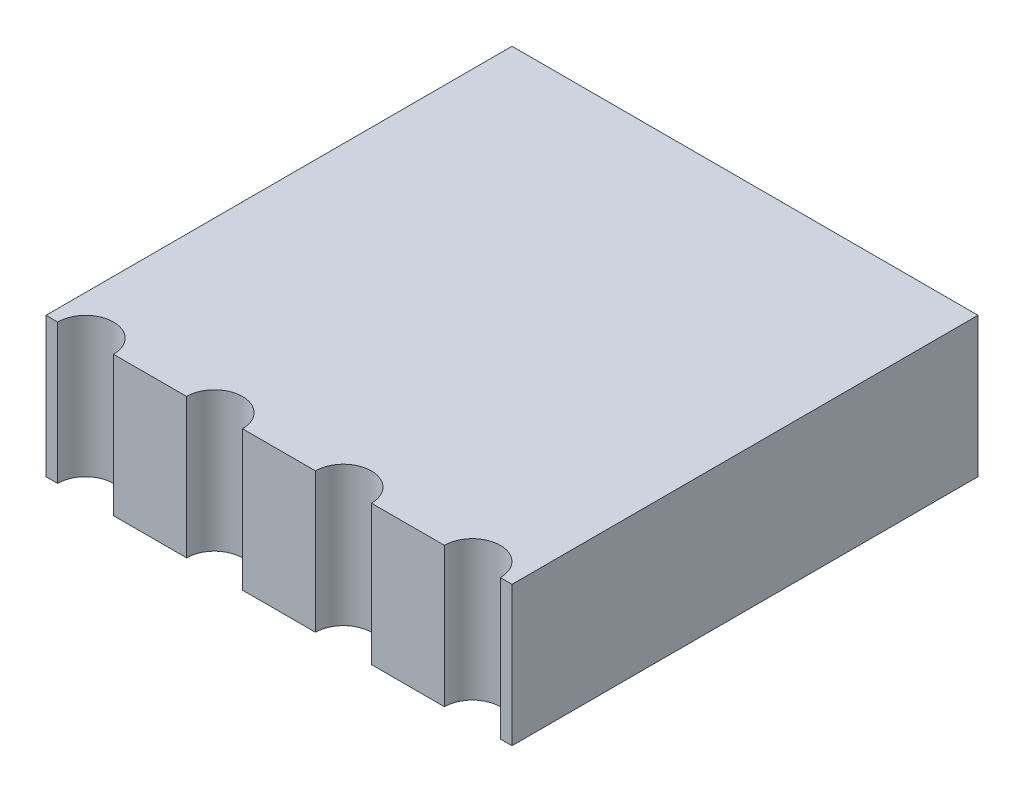
from build123d import *

# Parameters (mm, degrees)
SKETCH1_W           = 10
SKETCH1_H           = 10
BOSS_EXTRUDE1_DEPTH = 1.5
CUT_EXTRUDE1_DEPTH  = 1.5
LPATTERN1_COUNT     = 4
LPATTERN1_PITCH     = 2.766666667


with BuildPart() as part:
    # Sketch1 → Boss-Extrude1 (new body, symmetric)
    with BuildSketch(Plane(origin=(0, 0, 0), x_dir=(1, 0, 0), z_dir=(0, 1, 0))):
        Rectangle(SKETCH1_W, SKETCH1_H)
    extrude(amount=BOSS_EXTRUDE1_DEPTH, both=True)

    # Sketch2 → Cut-Extrude1 (cut, symmetric)
    with BuildSketch(Plane(origin=(0, 0, 0), x_dir=(1, 0, 0), z_dir=(0, 1, 0))):
        with BuildLine():
            Line((-4.75, -5), (-3.55, -5))
            ThreePointArc((-3.55, -5), (-4.15, -4.4), (-4.75, -5))
        make_face()
    cut_extrude1 = extrude(amount=CUT_EXTRUDE1_DEPTH, both=True, mode=Mode.SUBTRACT)

    # LPattern1: Cut-Extrude1 ×4
    with Locations(*[(i * LPATTERN1_PITCH, 0, 0) for i in range(1, LPATTERN1_COUNT)]):
        add(cut_extrude1, mode=Mode.SUBTRACT)


solid = part.part
